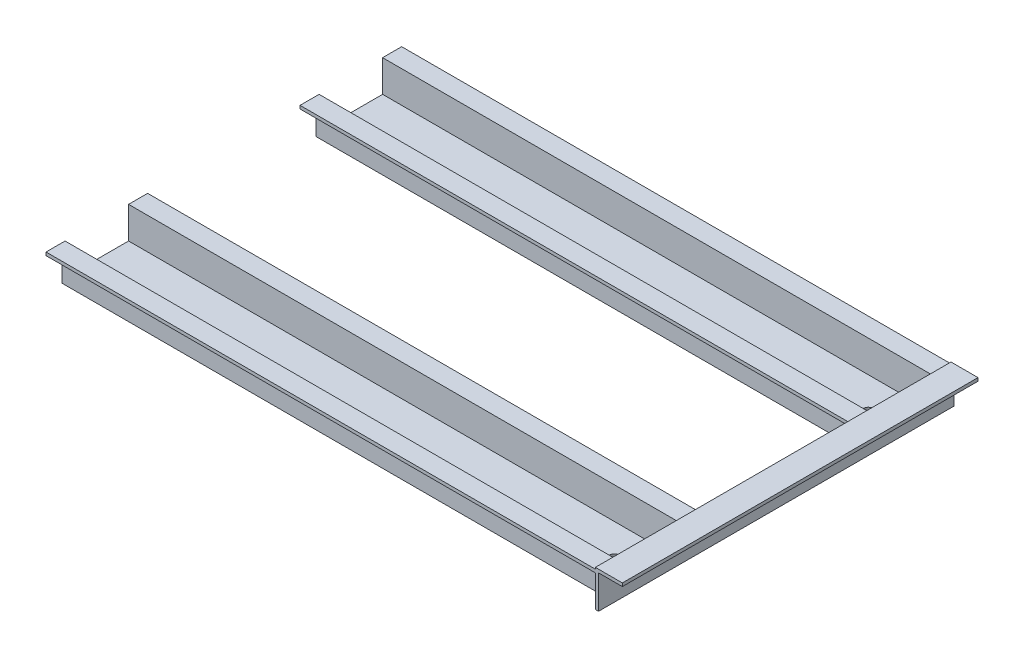
from build123d import *

# Parameters (mm, degrees)
EXTRUDE_THIN1_DEPTH     = 346
SKETCH5_R               = 3.3
CUT_EXTRUDE1_DEPTH      = 365.225205059
CUT_EXTRUDE1_DEPTH_BACK = 365.225205059
SKETCH6_W               = 23
SKETCH6_H               = 224
BOSS_EXTRUDE2_DEPTH     = 2
SKETCH8_W               = 2
SKETCH8_H               = 224
EXTRUDE_THIN2_DEPTH     = 15


with BuildPart() as part:
    # Sketch2 → Extrude-Thin1 (new body)
    with BuildSketch(Plane.YZ):
        Polygon((20, 112), (20, 102), (0, 102), (0, 58), (20, 58), (20, 48), (22, 48), (22, 60), (2, 60), (2, 100), (22, 100), (22, 112), align=None)
    extrude(amount=-EXTRUDE_THIN1_DEPTH)

    # Sketch5 → Cut-Extrude1 (cut, two sides)
    with BuildSketch(Plane(origin=(0, 2, 0), x_dir=(-1, 0, 0), z_dir=(0, 1, 0))) as cut_extrude1_sk:
        with Locations(Location((326, 80, 0), (0, 0, 90))):
            Circle(SKETCH5_R)
    extrude(amount=CUT_EXTRUDE1_DEPTH, mode=Mode.SUBTRACT)
    extrude(cut_extrude1_sk.sketch, amount=-CUT_EXTRUDE1_DEPTH_BACK, mode=Mode.SUBTRACT)


with BuildPart() as body_2:
    # Mirror1: mirrored copy
    add(part.part.mirror(Plane.XY))


with BuildPart() as part_1:
    add(part.part)

    add(body_2.part)  # Boss-Extrude2 merges body 2
    # Sketch6 → Boss-Extrude2 (add)
    with BuildSketch(Plane(origin=(-346, 0, 0), x_dir=(0, 1, 0), z_dir=(-1, 0, 0))):
        with Locations((11.5, 0)):
            Rectangle(SKETCH6_W, SKETCH6_H)
    extrude(amount=BOSS_EXTRUDE2_DEPTH)

    # Sketch8 → Extrude-Thin2 (add)
    with BuildSketch(Plane(origin=(-348, 0, 0), x_dir=(0, -1, 0), z_dir=(-1, 0, 0))):
        with Locations((-22, 0)):
            Rectangle(SKETCH8_W, SKETCH8_H)
    extrude(amount=EXTRUDE_THIN2_DEPTH)

    # Mirror2: part across plane


with BuildPart() as part_2:
    add(part_1.part)
    add(part_1.part.mirror(Plane(origin=(0, 0, 0), x_dir=(0, 0, 1), z_dir=(1, 0, 0))))

    # SurfaceCut1
    split(bisect_by=Plane.YZ, keep=Keep.TOP)


solid = part_2.part
